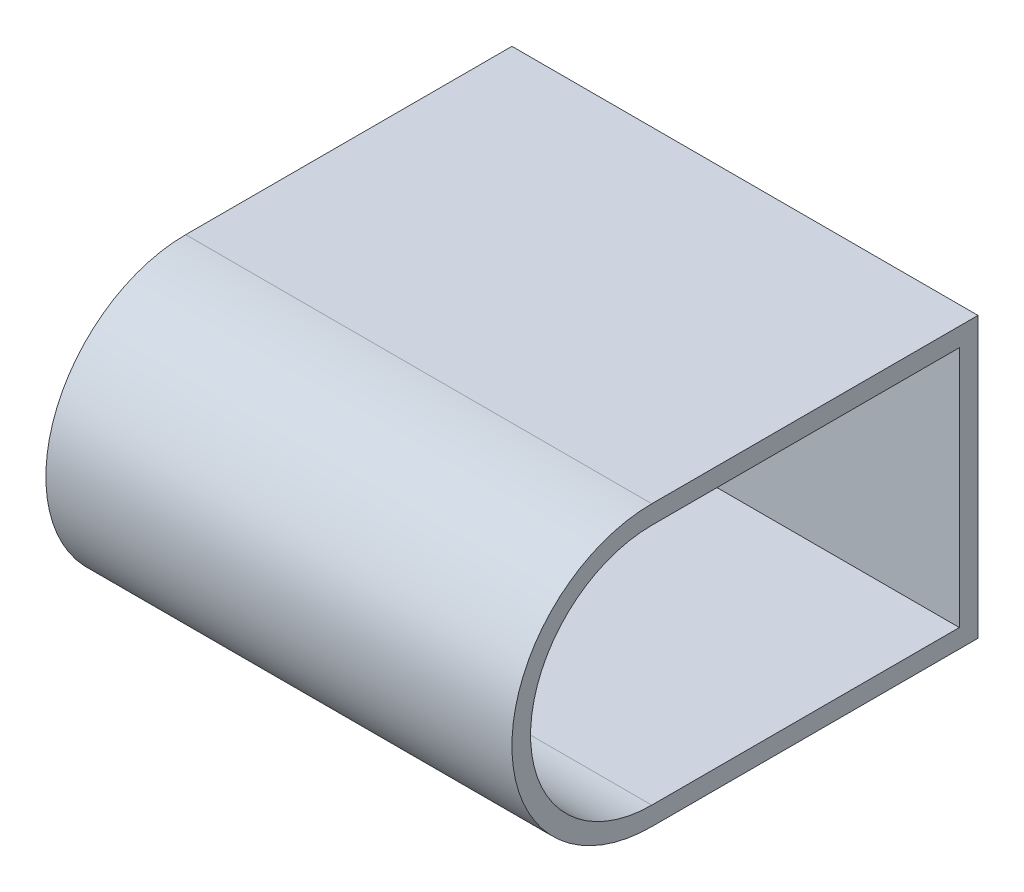
from build123d import *

# Parameters (mm, degrees)
TUBE_BISEAUT_TUBE_BISEAUT_1_1_DEPTH = 50
ESQUISSE12_R                        = 5
BOSS_EXTRU_1_DEPTH                  = 2


with BuildPart() as part:
    # Esquisse11 → Tube biseauté TUBE BISEAUTÉ 1(1) (new body)
    with BuildSketch(Plane.YZ):
        with BuildLine():
            Line((-15, 0), (-15, 35))
            ThreePointArc((-15, 35), (0, 50), (15, 35))
            Line((15, 35), (15, 0))
            Line((15, 0), (-15, 0))
        make_face()
        with BuildLine():
            Line((-13, 2), (-13, 35))
            ThreePointArc((-13, 35), (0, 48), (13, 35))
            Line((13, 35), (13, 2))
            Line((13, 2), (-13, 2))
        make_face(mode=Mode.SUBTRACT)
    extrude(amount=TUBE_BISEAUT_TUBE_BISEAUT_1_1_DEPTH)


with BuildPart() as body_2:
    # Esquisse12 → Boss.-Extru.1 (new body)
    with BuildSketch(Plane.ZY):
        with BuildLine():
            Line((35, -13), (2, -13))
            Line((2, -13), (2, 13))
            Line((2, 13), (35, 13))
            ThreePointArc((35, 13), (48, 0), (35, -13))
        make_face()
        with Locations((35, 0)):
            Circle(ESQUISSE12_R, mode=Mode.SUBTRACT)
    extrude(amount=-BOSS_EXTRU_1_DEPTH)


solid = Compound([part.part, body_2.part])
